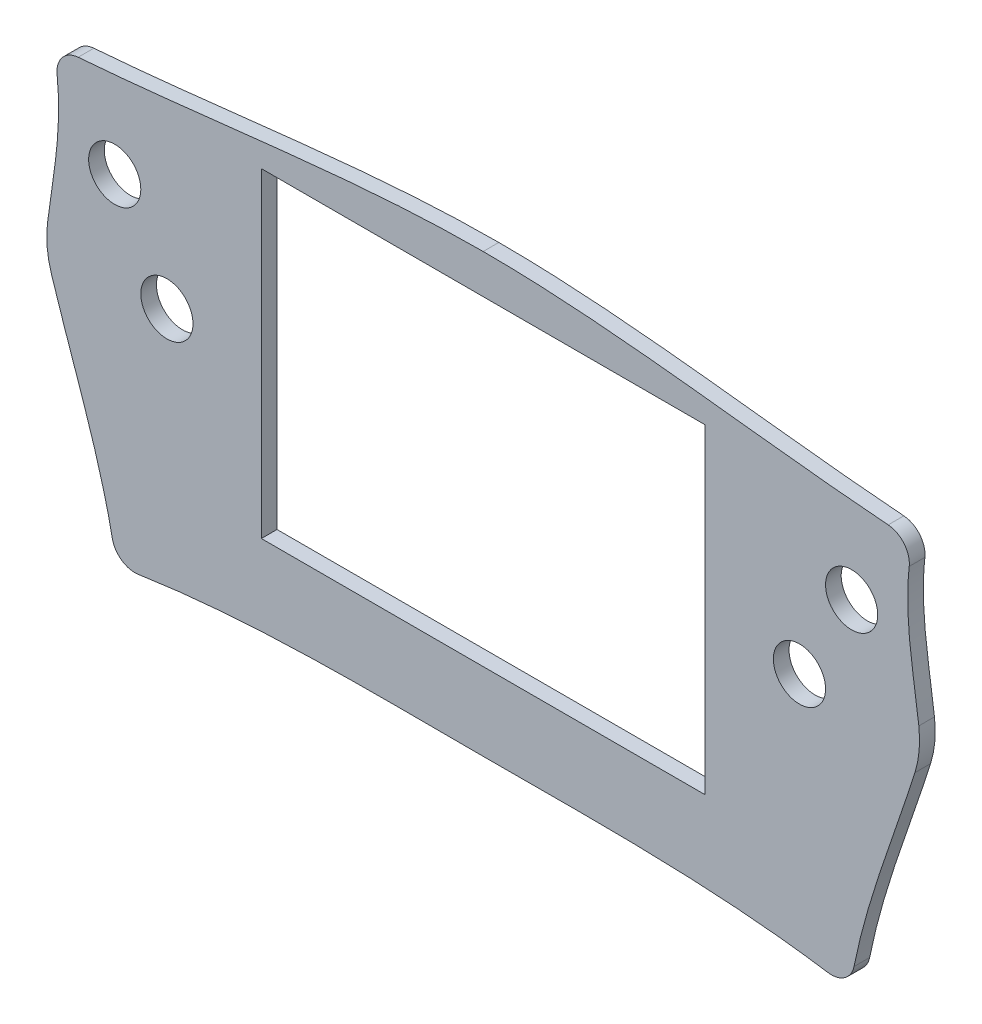
from build123d import *

# Parameters (mm, degrees)
SKETCH1_R           = 6.35
SKETCH1_W           = 107.95
SKETCH1_H           = 77.978
BOSS_EXTRUDE1_DEPTH = 3.81


with BuildPart() as part:
    # Sketch1 → Boss-Extrude1 (new body)
    with BuildSketch(Plane.XY):
        with BuildLine():
            ThreePointArc((-90.247945126, 1.580161299), (-87.975141882, -1.900637883), (-83.927585414, -2.848732901))
            add(Edge.make_bspline(
                [(-83.927585414, -2.848732901), (-83.054070471, -2.715786742), (-81.312732205, -2.460099658), (-78.654295906, -2.097457818), (-75.966491195, -1.758240891), (-72.336992818, -1.336160635), (-68.643939449, -0.959865866), (-65.583983691, -0.690535221), (-64.166779255, -0.573734085), (-63.566148315, -0.525577724), (-63.104217983, -0.489316665), (-62.699894104, -0.457970525), (-61.962459601, -0.401810292), (-60.915867879, -0.325087188), (-59.217621249, -0.20679221), (-57.068227268, -0.068668175), (-54.439670256, 0.082013873), (-51.767032951, 0.217415022), (-49.490906759, 0.318006821), (-48.009034739, 0.376639561), (-47.303600356, 0.403182815), (-46.87624745, 0.418937653), (-46.196192411, 0.443333549), (-45.175910497, 0.47801298), (-43.54019985, 0.529440772), (-41.442918551, 0.587830962), (-38.856544752, 0.647964805), (-36.195775126, 0.698343729), (-33.919375463, 0.73216057), (-32.406847373, 0.750213929), (-31.706246722, 0.757752509), (-31.408404648, 0.760817662), (-31.181163199, 0.763075054), (-31.021391801, 0.764629932), (-30.707730066, 0.767603553), (-30.26986268, 0.771505625), (-29.546357408, 0.777455403), (-28.619562792, 0.78413893), (-27.465024779, 0.791021083), (-25.871235622, 0.798660769), (-23.776420321, 0.805345875), (-21.095419523, 0.808788849), (-18.730229007, 0.807870354), (-16.988945077, 0.805198844), (-16.118237596, 0.803410927), (-15.586446283, 0.802172614), (-15.160582097, 0.801119107), (-14.629388092, 0.799779587), (-13.778859371, 0.797542602), (-12.290567631, 0.793391761), (-10.165619586, 0.786950406), (-7.609712384, 0.777596832), (-4.232901772, 0.76670962), (-1.692574695, 0.762894866), (-0.000735939, 0.762000495)],
                knots=[0.344883789, 0.344883789, 0.344883789, 0.344883789, 0.365355884, 0.385827978, 0.406300073, 0.426772167, 0.467716357, 0.488188451, 0.493306475, 0.498424499, 0.50098351, 0.503542522, 0.508660546, 0.518896593, 0.529132641, 0.549604735, 0.57007683, 0.590548924, 0.611021019, 0.621257066, 0.623816078, 0.62637509, 0.631493114, 0.641729161, 0.651965208, 0.672437303, 0.692909397, 0.713381492, 0.733853587, 0.744089634, 0.746648646, 0.749207658, 0.750487163, 0.751766669, 0.754325681, 0.759443705, 0.764561728, 0.774797776, 0.785033823, 0.79526987, 0.815741965, 0.83621406, 0.856686154, 0.866922202, 0.872040225, 0.874599237, 0.877158249, 0.882276272, 0.887394296, 0.897630343, 0.918102438, 0.938574533, 0.959046627, 0.999990816, 0.999990816, 0.999990816, 0.999990816], degree=3))
            add(Edge.make_bspline(
                [(-0.000735939, 0.762000495), (1.697316836, 0.766177734), (4.244409913, 0.77253852), (7.640476943, 0.781209392), (10.187668405, 0.787807526), (12.309879884, 0.793384892), (13.796306461, 0.797330932), (14.644321151, 0.799597123), (15.177550854, 0.80101974), (15.596748301, 0.802157809), (16.118287, 0.803504136), (16.973995966, 0.80545727), (18.68829658, 0.808424504), (21.027999055, 0.809635512), (23.697872289, 0.806345409), (25.799893716, 0.79962074), (27.409267347, 0.791849991), (28.580317931, 0.784820707), (29.525162279, 0.777971464), (30.265021199, 0.771870135), (30.715280941, 0.767851736), (31.035813921, 0.764814821), (31.203310927, 0.763185732), (31.424674383, 0.760990419), (31.725461502, 0.75790149), (32.424670998, 0.75038892), (33.939142843, 0.732342076), (36.215243056, 0.698563653), (38.877142881, 0.648210549), (41.464408025, 0.588096862), (43.562364845, 0.52972496), (45.199123553, 0.478290291), (46.218966314, 0.443646588), (46.900949422, 0.419191941), (47.325920748, 0.403533269), (48.032310107, 0.376969373), (49.513622078, 0.318385817), (51.790729101, 0.217796458), (54.463869347, 0.082412308), (57.093216384, -0.068273652), (59.243322334, -0.206412508), (60.942131401, -0.324720902), (61.989228303, -0.401465522), (62.726751965, -0.457620494), (63.131559362, -0.488998275), (63.592361081, -0.52516306), (64.193703385, -0.573365144), (65.61087209, -0.690141767), (68.671780552, -0.959508913), (72.365460908, -1.33583339), (75.995808252, -1.757987944), (78.68423516, -2.097273121), (81.343310776, -2.459998054), (83.085085672, -2.715750704), (83.958817154, -2.848731481)],
                knots=[9.152e-06, 9.152e-06, 9.152e-06, 9.152e-06, 0.040956877, 0.06143074, 0.081904603, 0.102378465, 0.112615397, 0.117733862, 0.122852328, 0.125411561, 0.127970794, 0.133089259, 0.143326191, 0.163800053, 0.184273916, 0.204747779, 0.21498471, 0.225221641, 0.235458573, 0.240577038, 0.245695504, 0.248254737, 0.249534353, 0.25081397, 0.253373202, 0.255932435, 0.266169367, 0.286643229, 0.307117092, 0.327590954, 0.348064817, 0.358301748, 0.36853868, 0.373657145, 0.376216378, 0.378775611, 0.389012542, 0.409486405, 0.429960268, 0.45043413, 0.470907993, 0.481144924, 0.491381856, 0.496500321, 0.499059554, 0.501618787, 0.506737253, 0.511855718, 0.532329581, 0.573277306, 0.593751169, 0.614225032, 0.634698894, 0.655172757, 0.655172757, 0.655172757, 0.655172757], degree=3))
            ThreePointArc((83.958817154, -2.848731481), (88.006379638, -1.900641004), (90.279187133, 1.58016116))
            add(Edge.make_bspline(
                [(90.279187133, 1.58016116), (90.707255223, 3.721330409), (91.671139987, 8.001579794), (93.903510476, 16.331728227), (97.14338237, 26.467199173), (100.58708015, 36.306691054), (103.244940111, 44.084996329), (104.500326759, 47.928352327), (105.108428455, 49.864950567)],
                knots=[-0.293557602, -0.293557602, -0.293557602, -0.293557602, -0.147731648, -0.001905695, 0.289746211, 0.581398118, 0.727224071, 0.873050024, 0.873050024, 0.873050024, 0.873050024], degree=3))
            ThreePointArc((105.108428455, 49.864950567), (106.136144084, 54.985756874), (106.061342514, 60.208137689))
            add(Edge.make_bspline(
                [(106.061342514, 60.208137689), (105.911666294, 61.444092118), (105.583988035, 63.887611007), (104.845109607, 68.962564326), (103.906894516, 75.52680744), (103.330597064, 82.448292199), (103.345249689, 87.49082735), (103.504349867, 90.423192606), (103.641008775, 91.919668099), (103.72344879, 92.661964135)],
                knots=[0.224037882, 0.224037882, 0.224037882, 0.224037882, 0.367934399, 0.511830915, 0.799623948, 1.087416981, 1.231313498, 1.303261756, 1.375210014, 1.375210014, 1.375210014, 1.375210014], degree=3))
            ThreePointArc((103.72344879, 92.661964135), (102.473247846, 96.843092134), (98.598214744, 98.850317136))
            add(Edge.make_bspline(
                [(98.598214744, 98.850317136), (94.416094473, 99.172048045), (86.049981349, 99.919191974), (69.422551197, 101.674055975), (48.779184165, 104.086919071), (28.344626534, 106.081432238), (12.109022695, 107.012529299), (4.052738444, 107.190075663), (0.015621033, 107.190075663)],
                knots=[0.21837869, 0.21837869, 0.21837869, 0.21837869, 0.316081353, 0.413784017, 0.609189345, 0.804594672, 0.902297336, 1, 1, 1, 1], degree=3))
            add(Edge.make_bspline(
                [(0.015621033, 107.190075663), (-4.021496378, 107.190075663), (-12.077780629, 107.012529299), (-28.313384468, 106.081432237), (-48.747942099, 104.08691907), (-69.39130913, 101.674055973), (-86.018739283, 99.919191972), (-94.384852407, 99.172048042), (-98.566972677, 98.850317134)],
                knots=[0, 0, 0, 0, 0.097702664, 0.195405328, 0.390810655, 0.586215983, 0.683918647, 0.78162131, 0.78162131, 0.78162131, 0.78162131], degree=3))
            ThreePointArc((-98.566972677, 98.850317134), (-102.442005779, 96.843092132), (-103.692206724, 92.661964133))
            add(Edge.make_bspline(
                [(-103.692206724, 92.661964133), (-103.609766709, 91.919668097), (-103.4731078, 90.423192604), (-103.314007622, 87.490827347), (-103.299354998, 82.448292195), (-103.875652451, 75.526807436), (-104.813867543, 68.962564321), (-105.552745972, 63.887611001), (-105.880424231, 61.444092112), (-106.030100451, 60.208137683)],
                knots=[-0.375210014, -0.375210014, -0.375210014, -0.375210014, -0.303261756, -0.231313498, -0.087416981, 0.200376052, 0.488169085, 0.632065601, 0.775962118, 0.775962118, 0.775962118, 0.775962118], degree=3))
            ThreePointArc((-106.030100451, 60.208137683), (-106.104902022, 54.985756873), (-105.077186396, 49.864950571))
            add(Edge.make_bspline(
                [(-105.077186396, 49.864950571), (-104.469084703, 47.928352336), (-103.213698061, 44.084996348), (-100.555838111, 36.306691093), (-97.112140347, 26.467199238), (-93.872268464, 16.33172832), (-91.63989798, 8.001579913), (-90.676013216, 3.721330541), (-90.247945126, 1.580161299)],
                knots=[0.126949976, 0.126949976, 0.126949976, 0.126949976, 0.272775929, 0.418601881, 0.710253787, 1.001905692, 1.147731645, 1.293557598, 1.293557598, 1.293557598, 1.293557598], degree=3))
        make_face()
        with Locations((-89.672260323, 78.615075663)):
            Circle(SKETCH1_R, mode=Mode.SUBTRACT)
        with Locations((89.703502388, 78.615075663)):
            Circle(SKETCH1_R, mode=Mode.SUBTRACT)
        with Locations((-76.972260323, 56.618030407)):
            Circle(SKETCH1_R, mode=Mode.SUBTRACT)
        with Locations((77.003502388, 56.618030407)):
            Circle(SKETCH1_R, mode=Mode.SUBTRACT)
        with Locations((0, 58.676075663)):
            Rectangle(SKETCH1_W, SKETCH1_H, mode=Mode.SUBTRACT)
    extrude(amount=BOSS_EXTRUDE1_DEPTH)


solid = part.part
